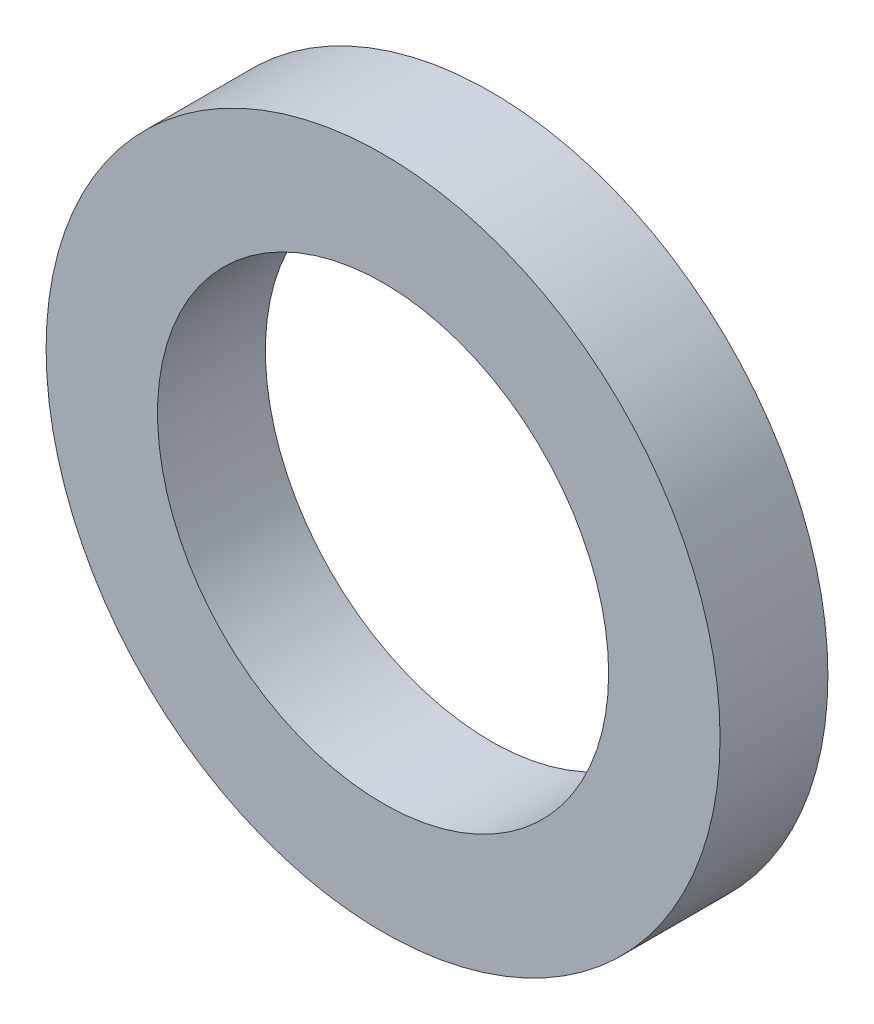
from build123d import *

# Parameters (mm, degrees)
SKETCH2_R           = 4.7625
SKETCH2_R_2         = 3.1877
BOSS_EXTRUDE1_DEPTH = 1.524


with BuildPart() as part:
    # Sketch2 → Boss-Extrude1 (new body)
    with BuildSketch(Plane.XY):
        Circle(SKETCH2_R)
        Circle(SKETCH2_R_2, mode=Mode.SUBTRACT)
    extrude(amount=BOSS_EXTRUDE1_DEPTH)


solid = part.part
